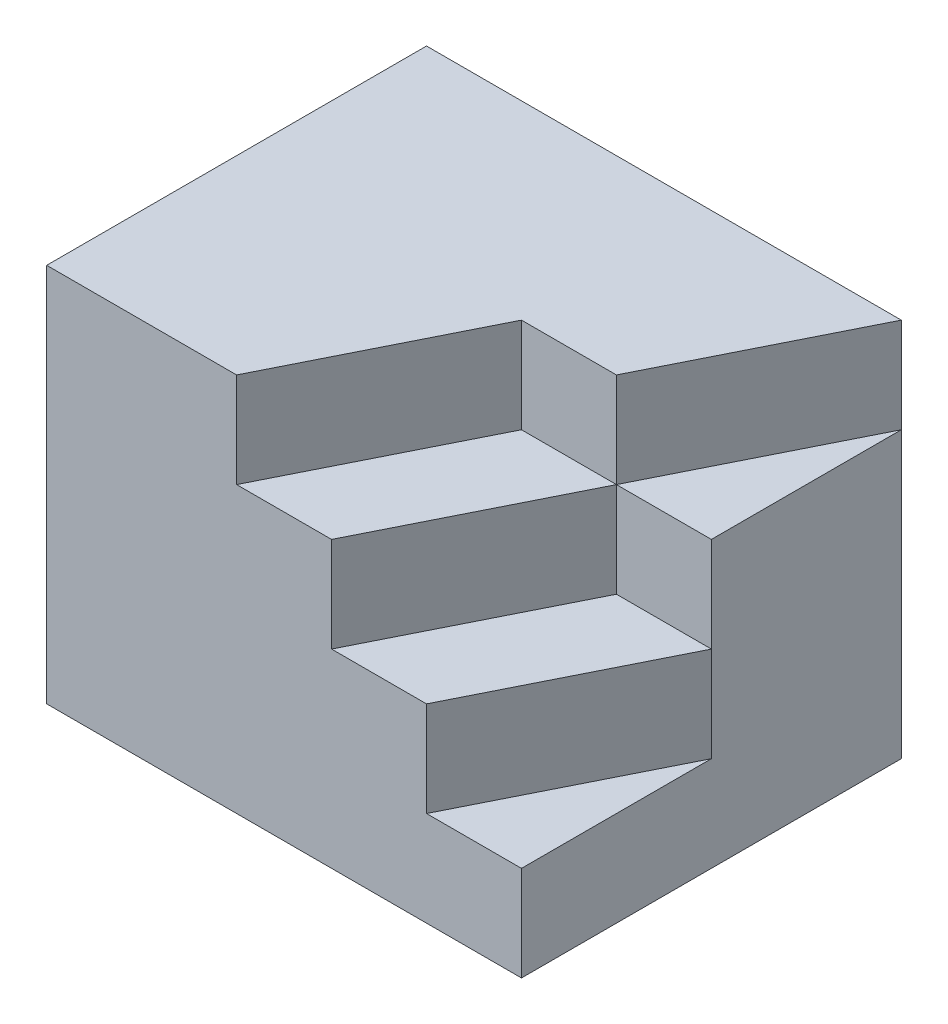
from build123d import *

# Parameters (mm, degrees)
SKETCH_1_W               = 50
SKETCH_1_H               = 40
EXTRUDE_1_DEPTH          = 40
CUT_EXTRUDE_1_DEPTH      = 30
CUT_EXTRUDE_2_DEPTH      = 20
CUT_EXTRUDE_3_DEPTH      = 10
CUT_EXTRUDE_4_DEPTH      = 52.23475383
CUT_EXTRUDE_4_DEPTH_BACK = 10


with BuildPart() as part:
    # 草圖1 → 填料-伸長1 (new body)
    with BuildSketch(Plane(origin=(0, 0, 0), x_dir=(1, 0, 0), z_dir=(0, 1, 0))):
        Rectangle(SKETCH_1_W, SKETCH_1_H)
    extrude(amount=EXTRUDE_1_DEPTH)

    # 草圖2 → 除料-伸長1 (cut)
    with BuildSketch(Plane(origin=(0, 40, 0), x_dir=(1, 0, 0), z_dir=(0, 1, 0))):
        Polygon((25, 0), (15, -20), (25, -20), align=None)
    extrude(amount=-CUT_EXTRUDE_1_DEPTH, mode=Mode.SUBTRACT)

    # 草圖3 → 除料-伸長2 (cut)
    with BuildSketch(Plane(origin=(0, 40, 0), x_dir=(1, 0, 0), z_dir=(0, 1, 0))):
        Polygon((25, 0), (15, 0), (5, -20), (15, -20), align=None)
    extrude(amount=-CUT_EXTRUDE_2_DEPTH, mode=Mode.SUBTRACT)

    # 草圖3<3> → 除料-伸長3 (cut)
    with BuildSketch(Plane(origin=(0, 40, 0), x_dir=(1, 0, 0), z_dir=(0, 1, 0))):
        Polygon((25, 0), (25, 20), (15, 0), align=None)
    extrude(amount=-CUT_EXTRUDE_3_DEPTH, mode=Mode.SUBTRACT)

    # 草圖4 → 除料-伸長4 (cut, two sides: drawn at the far end of the back side and taken through both)
    with BuildSketch(Plane(origin=(0, 40, 0), x_dir=(1, 0, 0), z_dir=(0, 1, 0)).offset(-CUT_EXTRUDE_4_DEPTH_BACK)):
        Polygon((125, 0), (15, 0), (5, 0), (-5, -20), (5, -20), (115, -20), (311.77398202, -118.38699101), (321.77398202, -98.38699101), align=None)
    extrude(amount=CUT_EXTRUDE_4_DEPTH + CUT_EXTRUDE_4_DEPTH_BACK, mode=Mode.SUBTRACT)


solid = part.part
